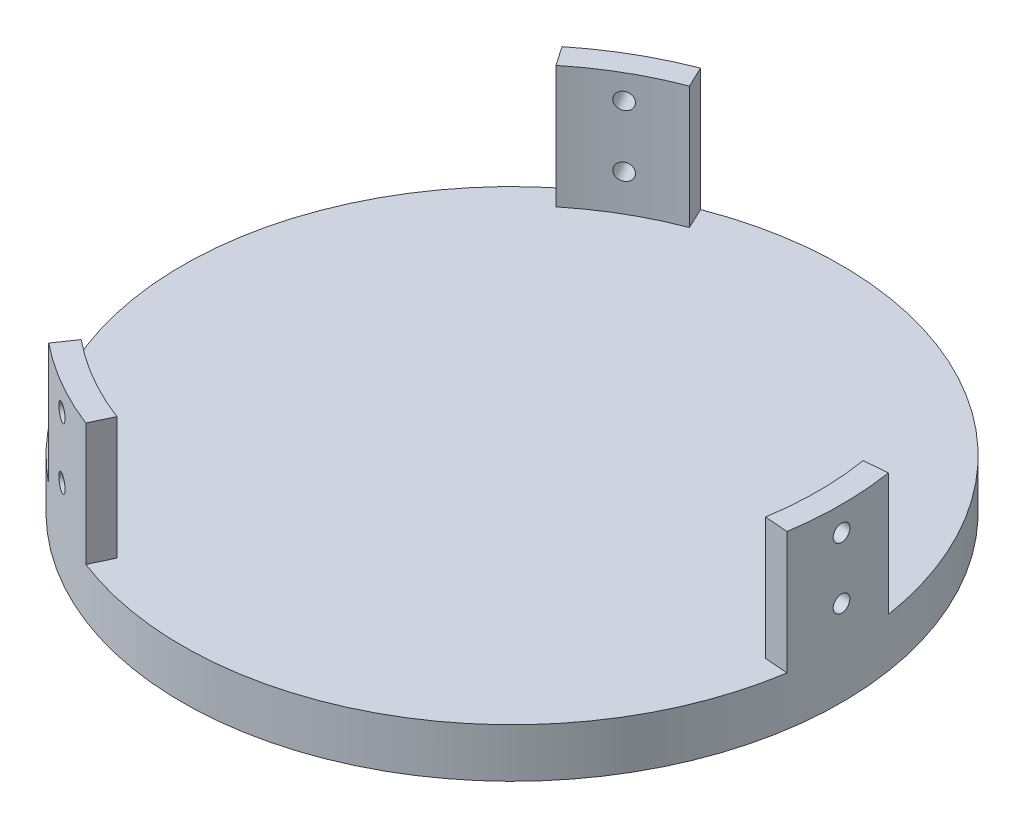
from build123d import *

# Parameters (mm, degrees)
SKETCH1_W           = 127.635
SKETCH1_H           = 127.635
MAIN_PLATE_DEPTH    = 12.7
SKETCH9_R           = 85.725
BOSS_EXTRUDE1_DEPTH = 12.7
SKETCH10_R          = 95.25
SKETCH10_R_2        = 85.4075
CUT_EXTRUDE1_DEPTH  = 167.64
SKETCH18_R          = 85.4075
SKETCH18_R_2        = 79.375
BOSS_EXTRUDE2_DEPTH = 38.1
SKETCH15_R          = 2.159
CUT_EXTRUDE3_DEPTH  = 88.9
CIRPATTERN1_COUNT   = 3
SKETCH23_R          = 79.375
CUT_EXTRUDE6_DEPTH  = 111.600000066


with BuildPart() as part:
    # Sketch1 → Main Plate (new body)
    with BuildSketch(Plane(origin=(0, 0, 0), x_dir=(1, 0, 0), z_dir=(0, 1, 0))):
        with Locations((63.8175, 63.8175)):
            Rectangle(SKETCH1_W, SKETCH1_H)
    extrude(amount=MAIN_PLATE_DEPTH)

    # Sketch9 → Boss-Extrude1 (add)
    with BuildSketch(Plane(origin=(0, 12.7, 0), x_dir=(1, 0, 0), z_dir=(0, 1, 0))):
        with Locations((63.8175, 63.8175)):
            Circle(SKETCH9_R)
    extrude(amount=-BOSS_EXTRUDE1_DEPTH)

    # Sketch10 → Cut-Extrude1 (cut)
    with BuildSketch(Plane(origin=(0, 12.7, 0), x_dir=(1, 0, 0), z_dir=(0, 1, 0))):
        with Locations((63.8175, 63.8175)):
            Circle(SKETCH10_R)
        with Locations((63.8175, 63.8175)):
            Circle(SKETCH10_R_2, mode=Mode.SUBTRACT)
    extrude(amount=-CUT_EXTRUDE1_DEPTH, mode=Mode.SUBTRACT)

    # Sketch18 → Boss-Extrude2 (add)
    with BuildSketch(Plane(origin=(0, 6.35, 0), x_dir=(1, 0, 0), z_dir=(0, 1, 0))):
        with Locations((63.8175, 63.8175)):
            Circle(SKETCH18_R)
        with Locations((63.8175, 63.8175)):
            Circle(SKETCH18_R_2, mode=Mode.SUBTRACT)
    extrude(amount=BOSS_EXTRUDE2_DEPTH)

    # Sketch15 → Cut-Extrude3 (cut)
    with BuildSketch(Plane(origin=(166.221610148, 0, 178.614251028), x_dir=(-0.866025404, 0, -0.5), z_dir=(0.5, 0, -0.866025404))):
        with Locations((209.900436354, 22.225)):
            Circle(SKETCH15_R)
        with Locations((209.900436354, 38.1)):
            Circle(SKETCH15_R)
    cut_extrude3 = extrude(amount=CUT_EXTRUDE3_DEPTH, mode=Mode.SUBTRACT)

    # CirPattern1: Cut-Extrude3 ×3 about axis
    cirpattern1_axis = Axis((63.8175, -154.94, -63.8175), (0, 1, 0))
    for i in range(1, CIRPATTERN1_COUNT):
        add(cut_extrude3.rotate(cirpattern1_axis, i * 360 / CIRPATTERN1_COUNT), mode=Mode.SUBTRACT)

    # Sketch23 → Cut-Extrude6 (cut)
    with BuildSketch(Plane(origin=(0, 12.7, 0), x_dir=(1, 0, 0), z_dir=(0, 1, 0))):
        with Locations((63.8175, 63.8175)):
            Circle(SKETCH23_R)
        with BuildLine():
            Line((13.678739997, 125.352005526), (7.552270878, 134.237860218))
            Line((7.552270878, 134.237860218), (-19.267108419, 125.320629884))
            Line((-19.267108419, 125.320629884), (-48.79695837, 60.397770071))
            Line((-48.79695837, 60.397770071), (-9.884344094, 7.052469015))
            Line((-9.884344094, 7.052469015), (6.959175986, -7.46308736))
            Line((6.959175986, -7.46308736), (13.678739997, 2.282994474))
            ThreePointArc((13.678739997, 2.282994474), (-15.5575, 63.8175), (13.678739997, 125.352005526))
        make_face()
        with BuildLine():
            Line((142.177324996, 76.471687114), (152.935935453, 77.334437661))
            Line((152.935935453, 77.334437661), (158.623077101, 105.019316613))
            Line((158.623077101, 105.019316613), (117.163156193, 163.054346747))
            Line((117.163156193, 163.054346747), (51.508463168, 156.027684783))
            Line((51.508463168, 156.027684783), (30.515862556, 148.698546693))
            Line((30.515862556, 148.698546693), (35.596435007, 138.00619264))
            ThreePointArc((35.596435007, 138.00619264), (103.505, 132.558266425), (142.177324996, 76.471687114))
        make_face()
        with BuildLine():
            Line((35.596435007, -10.37119264), (30.964293669, -20.119797879))
            Line((30.964293669, -20.119797879), (52.096531318, -38.887446496))
            Line((52.096531318, -38.887446496), (123.086302178, -31.999616818))
            Line((123.086302178, -31.999616818), (149.828380926, 28.372346201))
            Line((149.828380926, 28.372346201), (153.977461458, 50.217040667))
            Line((153.977461458, 50.217040667), (142.177324996, 51.163312886))
            ThreePointArc((142.177324996, 51.163312886), (103.505, -4.923266425), (35.596435007, -10.37119264))
        make_face()
    extrude(amount=CUT_EXTRUDE6_DEPTH, mode=Mode.SUBTRACT)


solid = part.part
